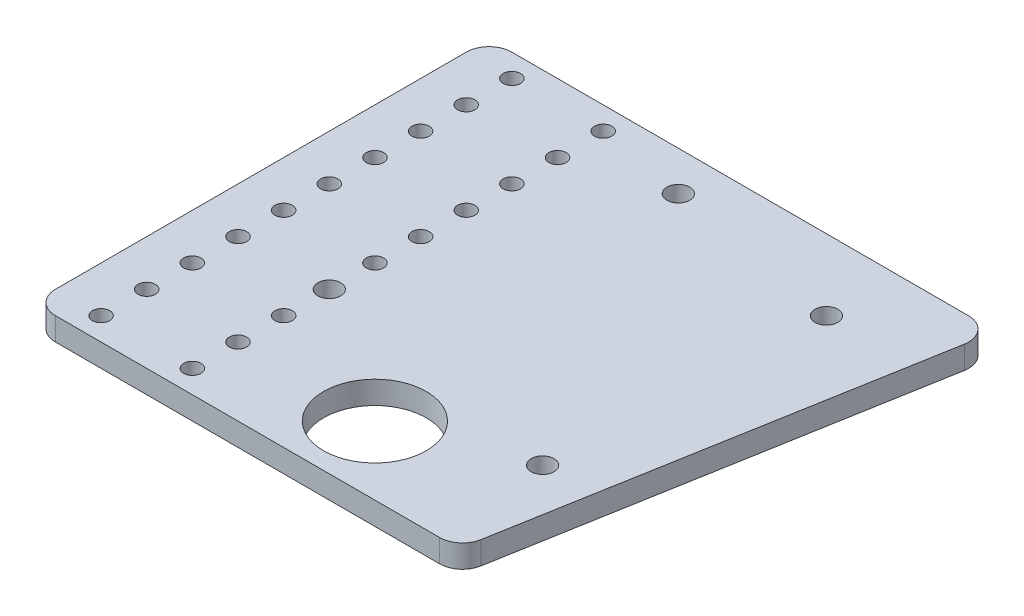
from build123d import *

# Parameters (mm, degrees)
INITIAL_PLATE_DEPTH         = 6.35
SKETCH3_R                   = 2.413
INITIAL_MOUNTING_HOLE_DEPTH = 7.35
MOUNTING_PATTERN_COUNT      = 10
MOUNTING_PATTERN_PITCH      = 12.7
SKETCH2_R                   = 3.175
BEARING_STACK_HOLES_DEPTH   = 7.35
FILLET1_R                   = 6.35
SKETCH4_R                   = 14.2875
CUT_EXTRUDE1_DEPTH          = 7.35


with BuildPart() as part:
    # Sketch1 → Initial Plate (new body)
    with BuildSketch(Plane(origin=(0, 0, 0), x_dir=(1, 0, 0), z_dir=(0, 1, 0))):
        Polygon((-64.403593083, -58.02125503), (54.172880367, -58.02125503), (76.566406917, 68.97874497), (-64.403593083, 68.97874497), align=None)
    extrude(amount=INITIAL_PLATE_DEPTH)

    # Sketch3 → Initial Mounting Hole (cut, through all)
    with BuildSketch(Plane(origin=(0, 6.35, 0), x_dir=(1, 0, 0), z_dir=(0, 1, 0))):
        with Locations((-51.703593083, -51.67125503)):
            Circle(SKETCH3_R)
        with Locations((-26.303593083, -51.67125503)):
            Circle(SKETCH3_R)
    initial_mounting_hole = extrude(amount=-INITIAL_MOUNTING_HOLE_DEPTH, mode=Mode.SUBTRACT)

    # Mounting Pattern: Initial Mounting Hole ×10
    with Locations(*[(0, 0, -i * MOUNTING_PATTERN_PITCH) for i in range(1, MOUNTING_PATTERN_COUNT)]):
        add(initial_mounting_hole, mode=Mode.SUBTRACT)

    # Sketch2 → Bearing Stack Holes (cut, through all)
    with BuildSketch(Plane(origin=(0, 6.35, 0), x_dir=(1, 0, 0), z_dir=(0, 1, 0))):
        with Locations((-26.303593083, -13.57125503)):
            Circle(SKETCH2_R)
        with Locations((49.243157186, 49.193730621)):
            Circle(SKETCH2_R)
        with Locations((45.737063665, -26.273966523)):
            Circle(SKETCH2_R)
        with Locations((-0.785076667, 58.015058047)):
            Circle(SKETCH2_R)
    extrude(amount=-BEARING_STACK_HOLES_DEPTH, mode=Mode.SUBTRACT)

    # Fillet1
    fillet1_edges = [part.edges().sort_by_distance(p)[0] for p in [
        (54.172880367, 3.175, 58.02125503),
        (-64.403593083, 3.175, 58.02125503),
        (-64.403593083, 3.175, -68.97874497),
        (76.566406917, 3.175, -68.97874497),
    ]]
    fillet(fillet1_edges, radius=FILLET1_R)

    # Sketch4 → Cut-Extrude1 (cut, through all)
    with BuildSketch(Plane(origin=(0, 6.35, 0), x_dir=(1, 0, 0), z_dir=(0, 1, 0))):
        with Locations((11.792603678, -38.977523898)):
            Circle(SKETCH4_R)
    extrude(amount=-CUT_EXTRUDE1_DEPTH, mode=Mode.SUBTRACT)


solid = part.part
